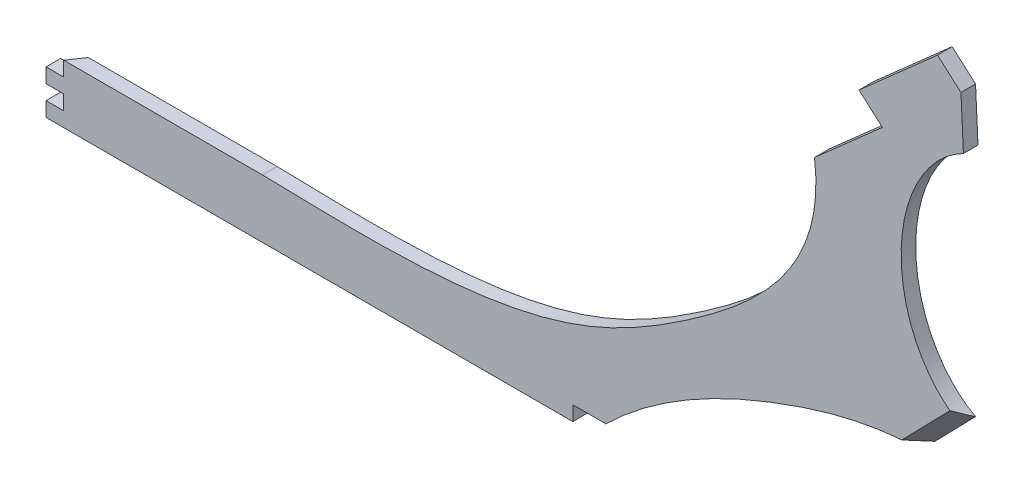
from build123d import *

# Parameters (mm, degrees)
BOSS_EXTRUDE1_DEPTH = 10
CUT_EXTRUDE1_DEPTH  = 10
SKETCH4_RX          = 87.174762469
SKETCH4_RY          = 66.453525419
CUT_EXTRUDE2_DEPTH  = 10
SKETCH5_W           = 26.438615702
SKETCH5_H           = 10
CUT_EXTRUDE5_DEPTH  = 30
SKETCH6_W           = 22.623740515
SKETCH6_H           = 10
CUT_EXTRUDE6_DEPTH  = 10


with BuildPart() as part:
    # Sketch1 → Boss-Extrude1 (new body)
    with BuildSketch(Plane.XY):
        with BuildLine():
            Line((-427.107921319, -118.031926349), (-575.271952131, -118.031926349))
            Line((-575.271952131, -118.031926349), (-575.271952131, -158.031926349))
            Line((-575.271952131, -158.031926349), (-192.080048862, -158.031926349))
            Line((-192.080048862, -158.031926349), (-192.080048862, -148.031926349))
            add(Edge.make_bspline(
                [(-192.080048862, -148.031926349), (-157.837008984, -114.51884489), (-75.168475425, -70.609825384), (16.241097891, -49.938935327), (61.818541816, -59.568417069)],
                knots=[0, 0, 0, 0, 0.513639289, 1, 1, 1, 1], degree=3))
            Line((61.818541816, -59.568417069), (50.930294818, 169.898138867))
            Line((50.930294818, 169.898138867), (34.940241092, 184.040274491))
            Line((34.940241092, 184.040274491), (-18.862584596, 136.455265033))
            Line((-18.862584596, 136.455265033), (-2.872530869, 122.313129409))
            Line((-2.872530869, 122.313129409), (-49.270535503, 81.277190105))
            add(Edge.make_bspline(
                [(-427.107921319, -118.031926349), (-356.64028899, -119.331018895), (-244.870528992, -125.219604065), (-108.651854921, -44.255191333), (-41.057154586, 17.202634848), (-49.270535503, 81.277190105)],
                knots=[0, 0, 0, 0, 0.468078311, 0.64359283, 1, 1, 1, 1], degree=3))
        make_face()
    extrude(amount=BOSS_EXTRUDE1_DEPTH)

    # Sketch2 → Cut-Extrude1 (cut, symmetric)
    with BuildSketch(Plane(origin=(28.004521107, -27.258908823, 34.059132337), x_dir=(0.8415259589150524, 0.33755828909978275, -0.4217682561930533), z_dir=(0.5402166791872512, -0.5258335661753164, 0.6570121766080502))):
        Polygon((55.096893941, -25.281928608), (25.403338602, -49.506612522), (-27.145369489, -41.573178566), (2.888217841, -17.531746483), (44.92299541, 24.503031085), (95.182381766, 9.000336469), align=None)
    extrude(amount=CUT_EXTRUDE1_DEPTH, both=True, mode=Mode.SUBTRACT)


with BuildPart() as cut_extrude1_kept_piece:
    # of the separate pieces the step leaves, the one the design keeps (cut_extrude1_pieces_kept)
    add(part.part.solids().sort_by_distance((-427.107921319, -118.031926349, 0))[0])

    # Sketch4 → Cut-Extrude2 (cut)
    with BuildSketch(Plane.XY.offset(10)):
        with Locations(Location((76.445934185, 53.167488188), (0, 0, -90))):
            Ellipse(SKETCH4_RX, SKETCH4_RY)
    extrude(amount=-CUT_EXTRUDE2_DEPTH, mode=Mode.SUBTRACT)

    # Sketch5 → Cut-Extrude5 (cut)
    with BuildSketch(Plane(origin=(-379.077692484, 0, -259.207509724), x_dir=(0.5644444444444446, 0, -0.8254710589328995), z_dir=(0.8254710589328994, 0, 0.5644444444444445))):
        with Locations((-327.230934206, -123.031926349)):
            Rectangle(SKETCH5_W, SKETCH5_H)
        with Locations((-327.230934206, -143.031926349)):
            Rectangle(SKETCH5_W, SKETCH5_H)
    extrude(amount=-CUT_EXTRUDE5_DEPTH, mode=Mode.SUBTRACT)

    # Sketch6 → Cut-Extrude6 (cut)
    with BuildSketch(Plane.XZ.offset(158.031926349)):
        with Locations((-203.39191912, 5)):
            Rectangle(SKETCH6_W, SKETCH6_H)
    extrude(amount=-CUT_EXTRUDE6_DEPTH, mode=Mode.SUBTRACT)


solid = cut_extrude1_kept_piece.part
